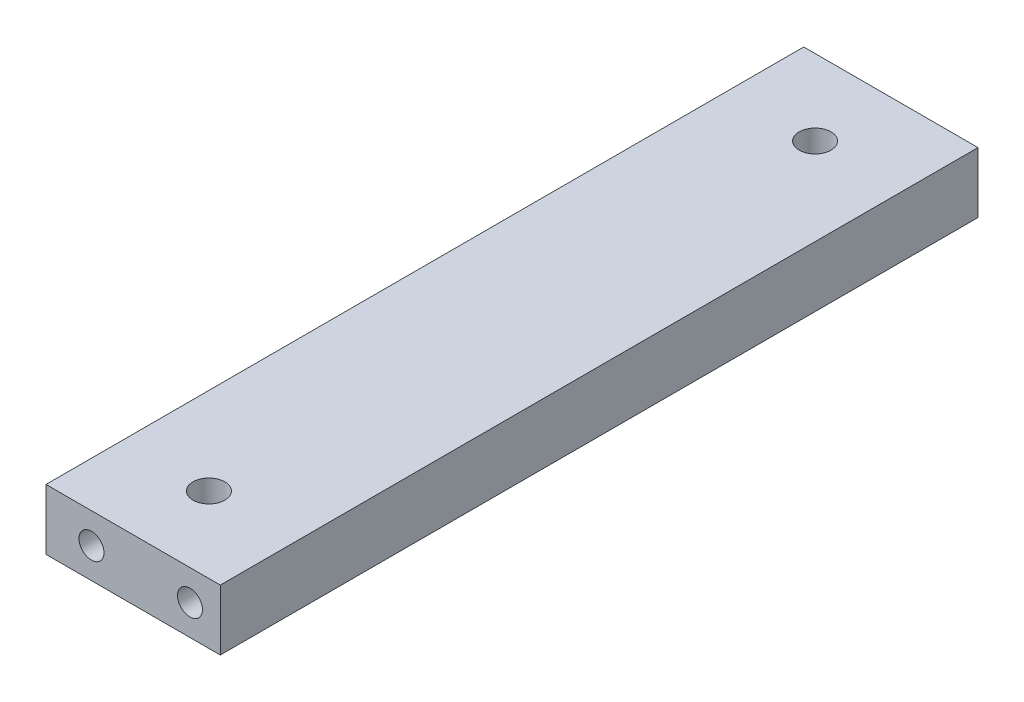
from build123d import *

# Parameters (mm, degrees)
SKETCH3_W                       = 23
SKETCH3_H                       = 8
EXTRUDE1_DEPTH                  = 100
M5_TAPPED_HOLE1_D               = 4.2
M4_TAPPED_HOLE1_D               = 3.3
M4_TAPPED_HOLE1_DEPTH           = 10
M4_TAPPED_HOLE1_TIP             = 0.991420021
M4_TAPPED_HOLE1_ON_FACE_2_D     = 3.3
M4_TAPPED_HOLE1_ON_FACE_2_DEPTH = 10
M4_TAPPED_HOLE1_ON_FACE_2_TIP   = 0.991420021
M3_TAPPED_HOLE1_REACH           = 25
M3_TAPPED_HOLE1_BORE_R          = 1.25


with BuildPart() as part:
    # Sketch3 → Extrude1 (new body)
    with BuildSketch(Plane.XY):
        with Locations((11.5, 4)):
            Rectangle(SKETCH3_W, SKETCH3_H)
    extrude(amount=EXTRUDE1_DEPTH)

    # M5 Tapped Hole1 (through all)
    with Locations(Plane(origin=(11.5, 8, 90), x_dir=(0, 0, 1), z_dir=(0, 1, 0))):
        with Locations((0, 0), (-80, 0)):
            Hole(M5_TAPPED_HOLE1_D / 2)

    # M4 Tapped Hole1
    with Locations(Plane(origin=(6, 4, 100), x_dir=(1, 0, 0), z_dir=(0, 0, 1))):
        with Locations((0, 0), (13, 0)):
            Hole(M4_TAPPED_HOLE1_D / 2, depth=M4_TAPPED_HOLE1_DEPTH)
            with Locations((0, 0, -(M4_TAPPED_HOLE1_DEPTH + M4_TAPPED_HOLE1_TIP / 2))):  # 118° drill point
                Cone(0, M4_TAPPED_HOLE1_D / 2, M4_TAPPED_HOLE1_TIP, mode=Mode.SUBTRACT)

    # M4 Tapped Hole1 on face 2
    with Locations(Plane(origin=(19, 4, 0), x_dir=(-1, 0, 0), z_dir=(0, 0, -1))):
        with Locations((0, 0), (15, 0)):
            Hole(M4_TAPPED_HOLE1_ON_FACE_2_D / 2, depth=M4_TAPPED_HOLE1_ON_FACE_2_DEPTH)
            with Locations((0, 0, -(M4_TAPPED_HOLE1_ON_FACE_2_DEPTH + M4_TAPPED_HOLE1_ON_FACE_2_TIP / 2))):  # 118° drill point
                Cone(0, M4_TAPPED_HOLE1_ON_FACE_2_D / 2, M4_TAPPED_HOLE1_ON_FACE_2_TIP, mode=Mode.SUBTRACT)

    # M3 Tapped Hole1 bore (on position points) → M3 Tapped Hole1 (cut, up to next)
    with BuildSketch(Plane(origin=(0, 4, 4), x_dir=(0, 0, -1), z_dir=(-1, 0, 0)), mode=Mode.PRIVATE) as m3_tapped_hole1_sk1:
        Circle(M3_TAPPED_HOLE1_BORE_R)
    m3_tapped_hole1_tool1 = extrude(m3_tapped_hole1_sk1.sketch, amount=-M3_TAPPED_HOLE1_REACH, mode=Mode.PRIVATE) & part.part
    add(m3_tapped_hole1_tool1.solids().sort_by_distance((0, 4, 4))[0], mode=Mode.SUBTRACT)


solid = part.part
